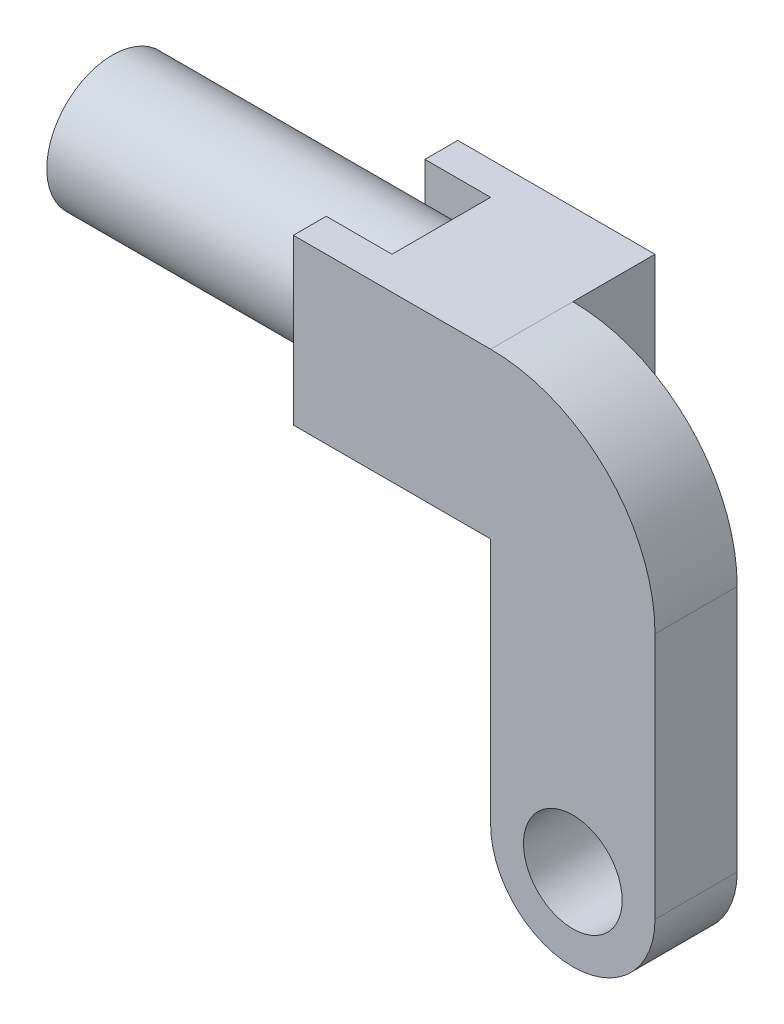
from build123d import *

# Parameters (mm, degrees)
SKETCH2_R           = 12.7
BOSS_EXTRUDE1_DEPTH = 63.5
SKETCH3_W           = 31.75
SKETCH3_H           = 31.75
BOSS_EXTRUDE2_DEPTH = 25.4
SKETCH6_W           = 12.7
SKETCH6_H           = 31.75
BOSS_EXTRUDE3_DEPTH = 6.35
SKETCH7_R           = 9.525
BOSS_EXTRUDE4_DEPTH = 15.875


with BuildPart() as part:
    # Sketch2 → Boss-Extrude1 (new body)
    with BuildSketch(Plane(origin=(0, 0, 0), x_dir=(0, 0, -1), z_dir=(1, 0, 0))):
        Circle(SKETCH2_R)
    extrude(amount=BOSS_EXTRUDE1_DEPTH)

    # Sketch3 → Boss-Extrude2 (add)
    with BuildSketch(Plane(origin=(63.5, 0, 0), x_dir=(0, 0, -1), z_dir=(1, 0, 0))):
        Rectangle(SKETCH3_W, SKETCH3_H)
    extrude(amount=BOSS_EXTRUDE2_DEPTH)

    # Sketch6 → Boss-Extrude3 (add)
    with BuildSketch(Plane(origin=(0, 0, -15.875), x_dir=(-1, 0, 0), z_dir=(0, 0, -1))):
        with Locations((-57.15, 0)):
            Rectangle(SKETCH6_W, SKETCH6_H)
    boss_extrude3 = extrude(amount=-BOSS_EXTRUDE3_DEPTH)

    # Mirror1: Boss-Extrude3 across plane
    add(boss_extrude3.mirror(Plane.XY))

    # Sketch7 → Boss-Extrude4 (add)
    with BuildSketch(Plane.XY.offset(15.875)):
        with BuildLine():
            Line((88.9, 15.875), (88.9, -63.627))
            ThreePointArc((88.9, -63.627), (104.775, -79.502), (120.65, -63.627))
            Line((120.65, -63.627), (120.65, -15.875))
            ThreePointArc((120.65, -15.875), (111.350640303, 6.575640303), (88.9, 15.875))
        make_face()
        with Locations((104.775, -63.627)):
            Circle(SKETCH7_R, mode=Mode.SUBTRACT)
    extrude(amount=-BOSS_EXTRUDE4_DEPTH)


solid = part.part
